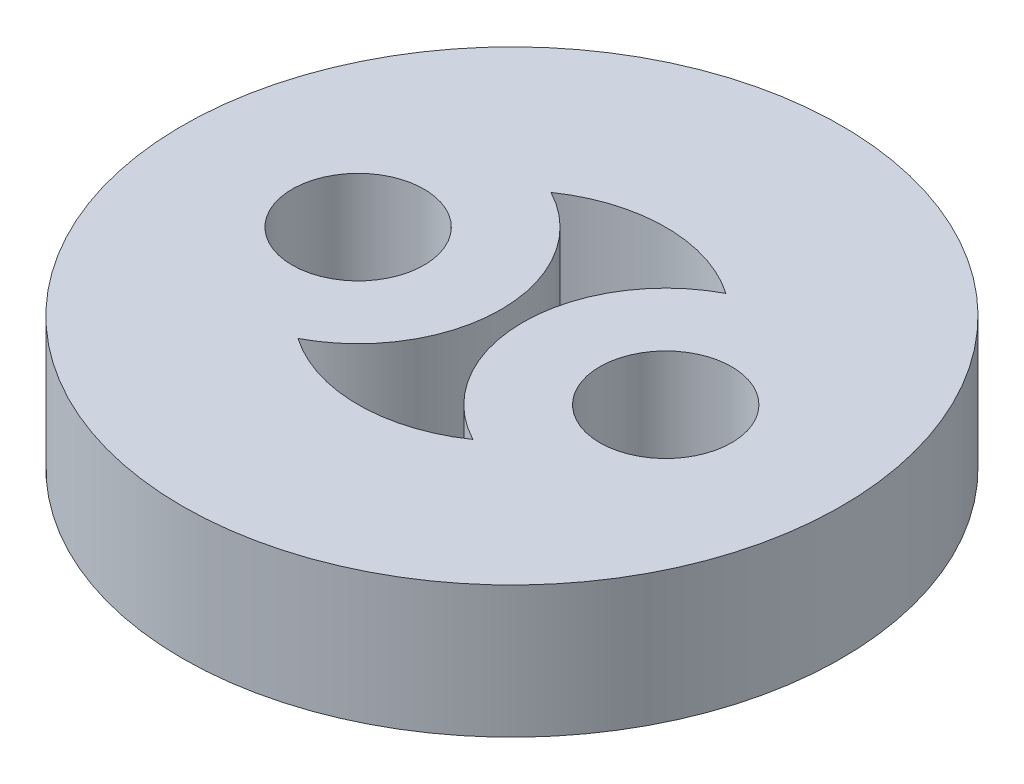
from build123d import *

# Parameters (mm, degrees)
ESQUISSE1_R        = 7.5
ESQUISSE1_R_2      = 1.5
BOSS_EXTRU_1_DEPTH = 3


with BuildPart() as part:
    # Esquisse1 → Boss.-Extru.1 (new body)
    with BuildSketch(Plane(origin=(0, 0, 0), x_dir=(1, 0, 0), z_dir=(0, 1, 0))):
        Circle(ESQUISSE1_R)
        with Locations((-3.5, 0)):
            Circle(ESQUISSE1_R_2, mode=Mode.SUBTRACT)
        with Locations((3.5, 0)):
            Circle(ESQUISSE1_R_2, mode=Mode.SUBTRACT)
        with BuildLine():
            ThreePointArc((1.991071429, 2.878477821), (0.25, 0), (1.991071429, -2.878477821))
            ThreePointArc((1.991071429, -2.878477821), (0, -3.5), (-1.991071429, -2.878477821))
            ThreePointArc((-1.991071429, -2.878477821), (-0.25, 0), (-1.991071429, 2.878477821))
            ThreePointArc((-1.991071429, 2.878477821), (0, 3.5), (1.991071429, 2.878477821))
        make_face(mode=Mode.SUBTRACT)
    extrude(amount=BOSS_EXTRU_1_DEPTH)


solid = part.part
